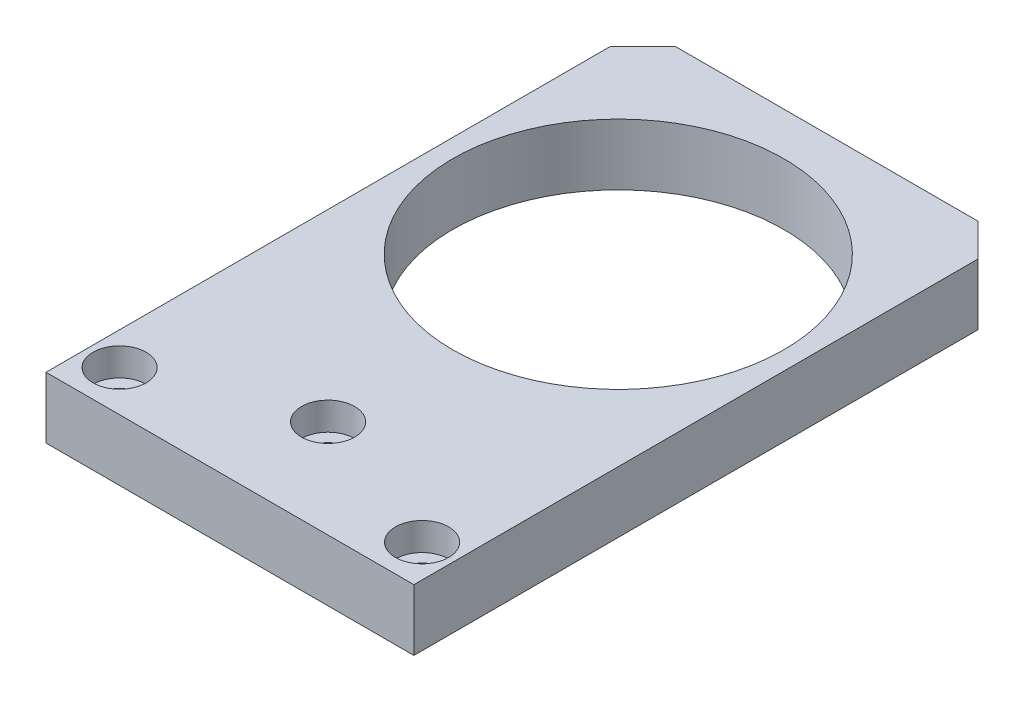
from build123d import *

# Parameters (mm, degrees)
SKETCH1_W                                           = 45
SKETCH1_H                                           = 73
SKETCH1_R                                           = 20.25
BOSS_EXTRUDE1_DEPTH                                 = 7.5
CHAMFER1_SIZE                                       = 4
CBORE_FOR_M3_HEX_SOCKET_HEAD_CAP_SCREW1_D           = 3.4
CBORE_FOR_M3_HEX_SOCKET_HEAD_CAP_SCREW1_DEPTH       = 7.5
CBORE_FOR_M3_HEX_SOCKET_HEAD_CAP_SCREW1_CBORE_D     = 6.5
CBORE_FOR_M3_HEX_SOCKET_HEAD_CAP_SCREW1_CBORE_DEPTH = 3.4


with BuildPart() as part:
    # Sketch1 → Boss-Extrude1 (new body)
    with BuildSketch(Plane(origin=(0, 0, 0), x_dir=(1, 0, 0), z_dir=(0, 1, 0))):
        with Locations((0, 36.5)):
            Rectangle(SKETCH1_W, SKETCH1_H)
        with Locations((0, 47.5)):
            Circle(SKETCH1_R, mode=Mode.SUBTRACT)
    extrude(amount=BOSS_EXTRUDE1_DEPTH)

    # Chamfer1
    chamfer1_edges = [part.edges().sort_by_distance(p)[0] for p in [
        (-22.5, 3.75, -73),
        (22.5, 3.75, -73),
    ]]
    chamfer(chamfer1_edges, length=CHAMFER1_SIZE)

    # CBORE for M3 Hex Socket Head Cap Screw1
    with Locations(Plane(origin=(0, 7.5, 0), x_dir=(1, 0, 0), z_dir=(0, 1, 0))):
        with Locations((-18.5, 5), (0, 12), (18.5, 5)):
            CounterBoreHole(CBORE_FOR_M3_HEX_SOCKET_HEAD_CAP_SCREW1_D / 2, CBORE_FOR_M3_HEX_SOCKET_HEAD_CAP_SCREW1_CBORE_D / 2, CBORE_FOR_M3_HEX_SOCKET_HEAD_CAP_SCREW1_CBORE_DEPTH, depth=CBORE_FOR_M3_HEX_SOCKET_HEAD_CAP_SCREW1_DEPTH)


solid = part.part
